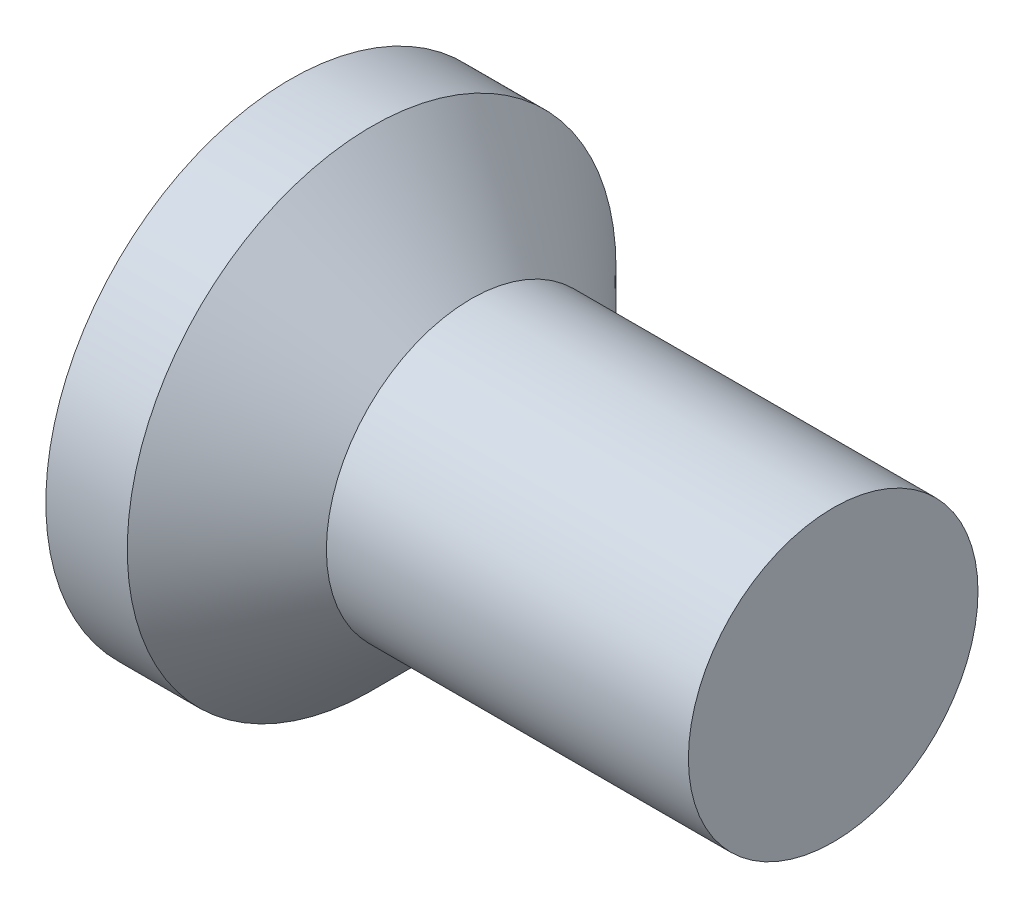
from build123d import *

# Parameters (mm, degrees)
CROSSRECESS_DEPTH = 0.5
DRAFT9_ANGLE      = 30
FILLET5_R         = 0.3


with BuildPart() as part:
    # Sketch1 → Base (revolve)
    with BuildSketch(Plane.XY):
        Polygon((3, 0.8), (1.7, 0.8), (1, 0.8), (0.45, 1.35), (0, 1.35), (0, 0), (3, 0), align=None)
    revolve(axis=Axis((4.515812911, 0, 0), (-1, 0, 0)))

    # Sketch6 → CrossRecess (cut)
    with BuildSketch(Plane(origin=(0, 0, 0), x_dir=(0, 0, -1), z_dir=(1, 0, 0))):
        Polygon((0.16, 0.16), (0.16, 0.8), (-0.16, 0.8), (-0.16, 0.16), (-0.8, 0.16), (-0.8, -0.16), (-0.16, -0.16), (-0.16, -0.8), (0.16, -0.8), (0.16, -0.16), (0.8, -0.16), (0.8, 0.16), align=None)
    extrude(amount=CROSSRECESS_DEPTH, mode=Mode.SUBTRACT)

    # Draft9
    draft9_faces = [part.faces().sort_by_distance(p)[0] for p in [
        (0.25, 0.8, 0),
        (0.25, 0, 0.8),
        (0.25, -0.8, 0),
        (0.25, 0, -0.8),
    ]]
    draft(draft9_faces, Plane(origin=(0, 1.35, 0), x_dir=(0, 0, -1), z_dir=(-1, 0, 0)), DRAFT9_ANGLE)

    # Fillet5
    fillet5_edges = [part.edges().sort_by_distance(p)[0] for p in [
        (0.25, 0.16, 0.16),
        (0.25, -0.16, 0.16),
        (0.25, -0.16, -0.16),
        (0.25, 0.16, -0.16),
    ]]
    fillet(fillet5_edges, radius=FILLET5_R)


solid = part.part
